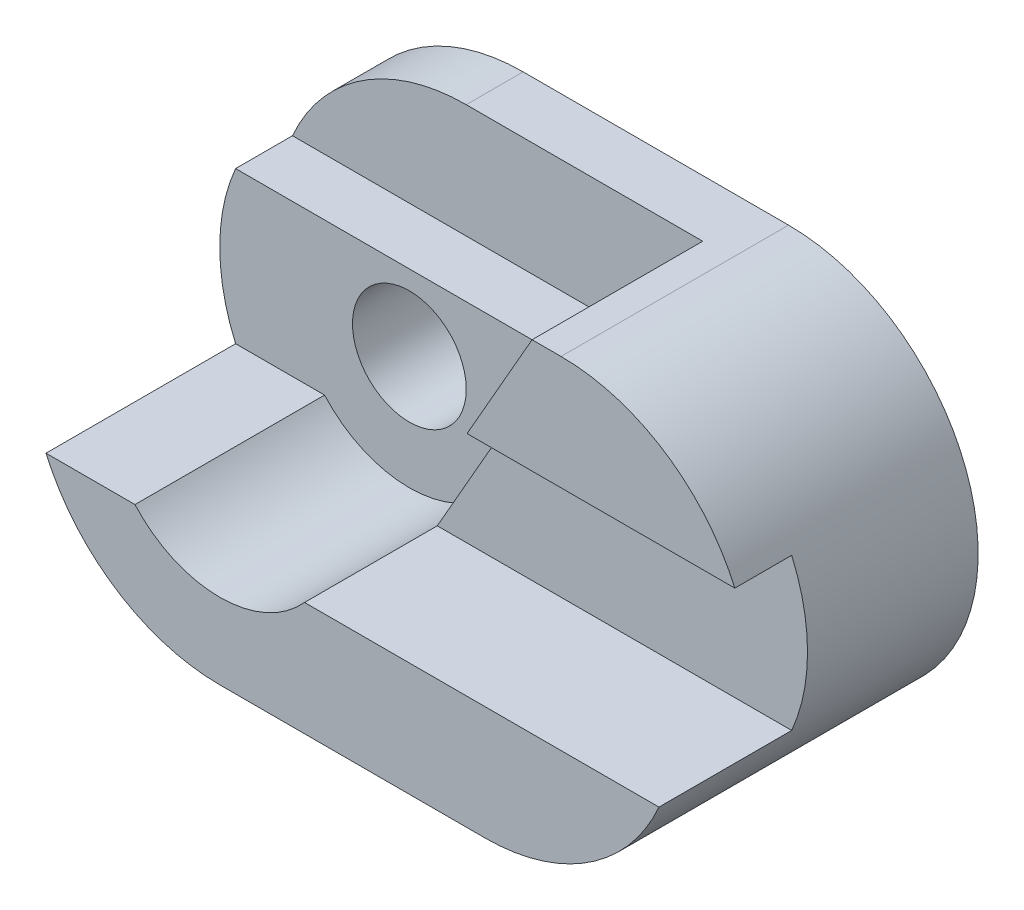
from build123d import *

# Parameters (mm, degrees)
SKETCH2_R               = 1.5
BOSS_EXTRUDE1_DEPTH     = 8
CUT_EXTRUDE1_DEPTH      = 18
CUT_EXTRUDE1_DEPTH_BACK = 18
CUT_EXTRUDE2_DEPTH      = 5
CUT_EXTRUDE3_DEPTH      = 1.5


with BuildPart() as part:
    # Sketch2 → Boss-Extrude1 (new body)
    with BuildSketch(Plane.XY):
        with BuildLine():
            Line((-3.5, 5), (3.5, 5))
            ThreePointArc((3.5, 5), (8.5, 0), (3.5, -5))
            Line((3.5, -5), (-3.5, -5))
            ThreePointArc((-3.5, -5), (-8.5, 0), (-3.5, 5))
        make_face()
        with Locations((-3.5, 0)):
            Circle(SKETCH2_R, mode=Mode.SUBTRACT)
    extrude(amount=BOSS_EXTRUDE1_DEPTH)

    # Sketch3 → Cut-Extrude1 (cut, two sides: drawn at the far end of the back side and taken through both)
    with BuildSketch(Plane(origin=(0, 0, 0), x_dir=(0, 0, -1), z_dir=(1, 0, 0)).offset(-CUT_EXTRUDE1_DEPTH_BACK)):
        Polygon((-8, -2), (-4.5, -2), (-4.5, 2), (-6, 2), (-6, 5), (-8, 5), align=None)
    extrude(amount=CUT_EXTRUDE1_DEPTH + CUT_EXTRUDE1_DEPTH_BACK, mode=Mode.SUBTRACT)

    # Sketch4 → Cut-Extrude2 (cut)
    with BuildSketch(Plane.XY.offset(8)):
        with BuildLine():
            Line((-1.263932023, -2), (2.736067977, 5))
            Line((2.736067977, 5), (-10.787192153, 5))
            Line((-10.787192153, 5), (-10.787192153, -2))
            Line((-10.787192153, -2), (-5.736067977, -2))
            ThreePointArc((-5.736067977, -2), (-3.5, -3), (-1.263932023, -2))
        make_face()
    extrude(amount=-CUT_EXTRUDE2_DEPTH, mode=Mode.SUBTRACT)

    # Sketch5 → Cut-Extrude3 (cut)
    with BuildSketch(Plane.XY.offset(3)):
        Polygon((1.021782263, 2), (2.736067977, 5), (-9.199414094, 5), (-9.199414094, 2), align=None)
    extrude(amount=-CUT_EXTRUDE3_DEPTH, mode=Mode.SUBTRACT)


solid = part.part
